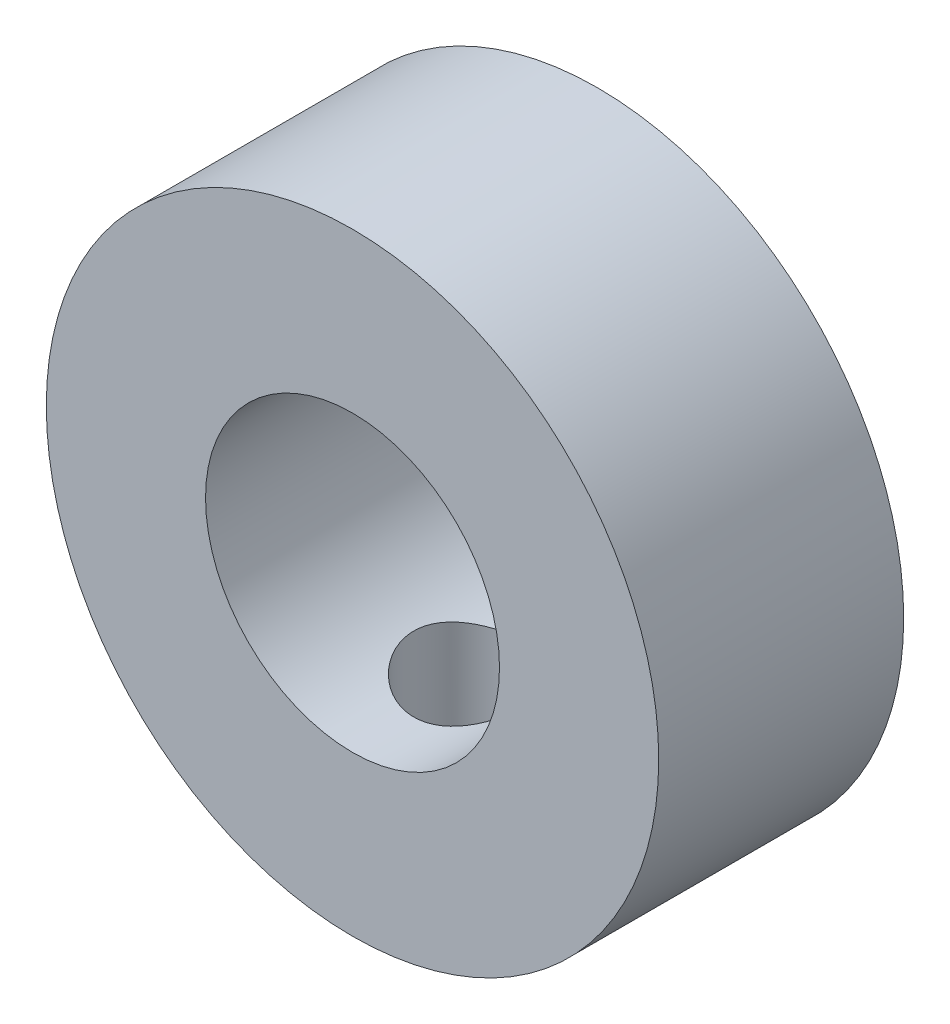
from build123d import *

# Parameters (mm, degrees)
SKETCH_1_R               = 12.5
SKETCH_1_R_2             = 6
EXTRUDE_1_DEPTH          = 10
CUT_EXTRUDE_1_DEPTH      = 10
CUT_EXTRUDE_1_DEPTH_BACK = 21.310096012
SKETCH_2_R               = 2.5


with BuildPart() as part:
    # 草图1 → 凸台-拉伸1 (new body)
    with BuildSketch(Plane.XY):
        Circle(SKETCH_1_R)
        Circle(SKETCH_1_R_2, mode=Mode.SUBTRACT)
    extrude(amount=EXTRUDE_1_DEPTH)

    # 草图2 → 切除-拉伸1 (cut, two sides: drawn at the far end of the back side and taken through both)
    with BuildSketch(Plane(origin=(0, 0, 0), x_dir=(1, 0, 0), z_dir=(0, 1, 0)).offset(-CUT_EXTRUDE_1_DEPTH_BACK)):
        with Locations((0, -5)):
            Circle(SKETCH_2_R)
    extrude(amount=CUT_EXTRUDE_1_DEPTH + CUT_EXTRUDE_1_DEPTH_BACK, mode=Mode.SUBTRACT)


solid = part.part
